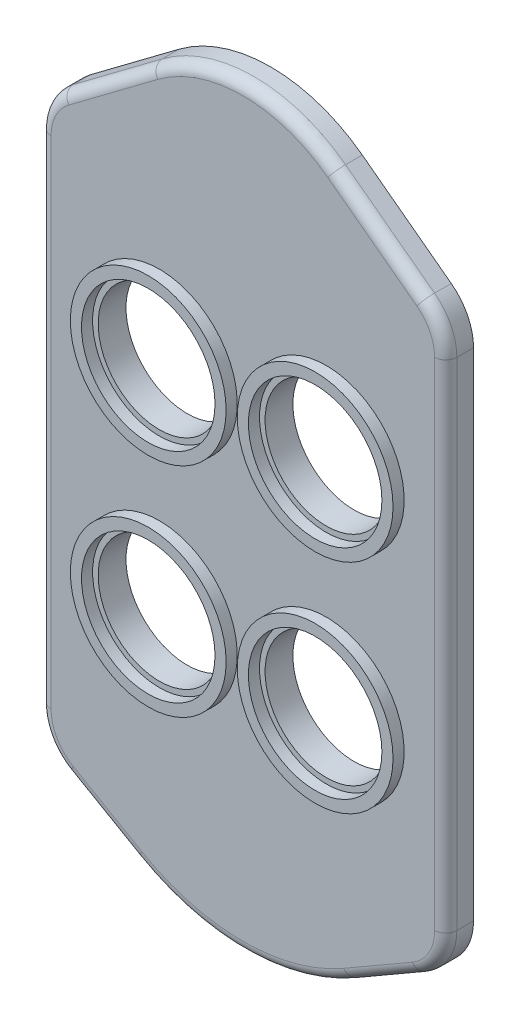
from build123d import *

# Parameters (mm, degrees)
BOSS_EXTRUDE4_DEPTH = 2.5
SKETCH7_R           = 11
CUT_EXTRUDE1_DEPTH  = 6
SKETCH8_R           = 14
SKETCH8_R_2         = 12
BOSS_EXTRUDE5_DEPTH = 2
FILLET1_R           = 2


with BuildPart() as part:
    # Sketch6 → Boss-Extrude4 (new body, symmetric)
    with BuildSketch(Plane.XY):
        with BuildLine():
            Line((-32.469344609, 53), (-16.469344609, 65))
            ThreePointArc((-16.469344609, 65), (0, 70.489781536), (16.469344609, 65))
            Line((16.469344609, 65), (32.469344609, 53))
            ThreePointArc((32.469344609, 53), (35.413616519, 49.472135955), (36.469344609, 45))
            Line((36.469344609, 45), (36.469344609, -44.226497308))
            ThreePointArc((36.469344609, -44.226497308), (35.129598647, -49.226497308), (31.469344609, -52.886751346))
            Line((31.469344609, -52.886751346), (19.148836533, -60))
            ThreePointArc((19.148836533, -60), (0, -65.130915285), (-19.148836533, -60))
            Line((-19.148836533, -60), (-31.469344609, -52.886751346))
            ThreePointArc((-31.469344609, -52.886751346), (-35.129598647, -49.226497308), (-36.469344609, -44.226497308))
            Line((-36.469344609, -44.226497308), (-36.469344609, 45))
            ThreePointArc((-36.469344609, 45), (-35.413616519, 49.472135955), (-32.469344609, 53))
        make_face()
    extrude(amount=BOSS_EXTRUDE4_DEPTH, both=True)

    # Sketch7 → Cut-Extrude1 (cut, through all)
    with BuildSketch(Plane.XY.offset(2.5)):
        with Locations((15, -19.159106742)):
            Circle(SKETCH7_R)
        with Locations((-15, -19.159106742)):
            Circle(SKETCH7_R)
        with Locations((-15, 20)):
            Circle(SKETCH7_R)
        with Locations((15, 20)):
            Circle(SKETCH7_R)
    extrude(amount=-CUT_EXTRUDE1_DEPTH, mode=Mode.SUBTRACT)

    # Sketch8 → Boss-Extrude5 (add)
    with BuildSketch(Plane.XY.offset(2.5)):
        with Locations((15, -19.159106742)):
            Circle(SKETCH8_R)
        with Locations((15, -19.159106742)):
            Circle(SKETCH8_R_2, mode=Mode.SUBTRACT)
        with Locations((-15, 20)):
            Circle(SKETCH8_R)
        with Locations((-15, 20)):
            Circle(SKETCH8_R_2, mode=Mode.SUBTRACT)
        with Locations((15, 20)):
            Circle(SKETCH8_R)
        with Locations((15, 20)):
            Circle(SKETCH8_R_2, mode=Mode.SUBTRACT)
        with Locations((-15, -19.159106742)):
            Circle(SKETCH8_R)
        with Locations((-15, -19.159106742)):
            Circle(SKETCH8_R_2, mode=Mode.SUBTRACT)
    extrude(amount=BOSS_EXTRUDE5_DEPTH)

    # Fillet1
    fillet1_edges = [part.edges().sort_by_distance(p)[0] for p in [
        (-35.413616519, 49.472135955, 2.5),
        (-36.469344609, 0.386751346, 2.5),
        (-35.129598647, -49.226497308, 2.5),
        (-25.309090571, -56.443375673, 2.5),
        (0, -65.130915285, 2.5),
        (25.309090571, -56.443375673, 2.5),
        (35.129598647, -49.226497308, 2.5),
        (36.469344609, 0.386751346, 2.5),
        (35.413616519, 49.472135955, 2.5),
        (24.469344609, 59, 2.5),
        (0, 70.489781536, 2.5),
        (-24.469344609, 59, 2.5),
    ]]
    fillet(fillet1_edges, radius=FILLET1_R)


solid = part.part
